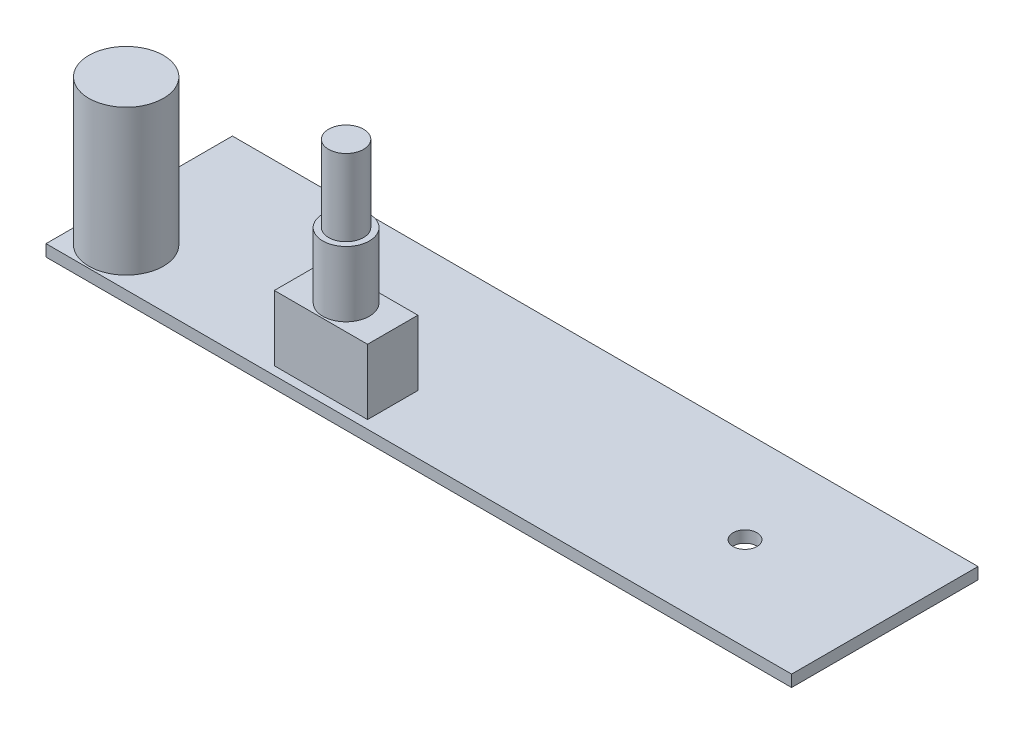
from build123d import *

# Parameters (mm, degrees)
SKETCH1_W                 = 101.6
SKETCH1_H                 = 25.4
BOSS_EXTRUDE1_DEPTH       = 1.5875
F_4_CLEARANCE_HOLE2_D     = 3.2639
F_4_CLEARANCE_HOLE2_DEPTH = 1.5875
SKETCH5_R                 = 5.08
BOSS_EXTRUDE2_DEPTH       = 19.812
SKETCH6_W                 = 12.7
SKETCH6_H                 = 6.858
BOSS_EXTRUDE3_DEPTH       = 8.89
SKETCH7_R                 = 3.175
BOSS_EXTRUDE4_DEPTH       = 8.89
SKETCH8_R                 = 2.38125
BOSS_EXTRUDE5_DEPTH       = 10.414


with BuildPart() as part:
    # Sketch1 → Boss-Extrude1 (new body)
    with BuildSketch(Plane(origin=(0, 0, 0), x_dir=(1, 0, 0), z_dir=(0, 1, 0))):
        with Locations((50.8, 12.7)):
            Rectangle(SKETCH1_W, SKETCH1_H)
    extrude(amount=BOSS_EXTRUDE1_DEPTH)

    # #4 Clearance Hole2
    with Locations(Plane(origin=(0, 1.5875, 0), x_dir=(1, 0, 0), z_dir=(0, 1, 0))):
        with Locations((31.75, 12.7), (82.55, 12.7)):
            Hole(F_4_CLEARANCE_HOLE2_D / 2, depth=F_4_CLEARANCE_HOLE2_DEPTH)

    # Sketch5 → Boss-Extrude2 (add)
    with BuildSketch(Plane(origin=(0, 1.5875, 0), x_dir=(1, 0, 0), z_dir=(0, 1, 0))):
        with Locations((5.588, 5.334)):
            Circle(SKETCH5_R)
    extrude(amount=BOSS_EXTRUDE2_DEPTH)

    # Sketch6 → Boss-Extrude3 (add)
    with BuildSketch(Plane(origin=(0, 1.5875, 0), x_dir=(1, 0, 0), z_dir=(0, 1, 0))):
        with Locations((36.322, 4.572)):
            Rectangle(SKETCH6_W, SKETCH6_H)
    extrude(amount=BOSS_EXTRUDE3_DEPTH)

    # Sketch7 → Boss-Extrude4 (add)
    with BuildSketch(Plane(origin=(0, 10.4775, 0), x_dir=(1, 0, 0), z_dir=(0, 1, 0))):
        with Locations((36.322, 4.572)):
            Circle(SKETCH7_R)
    extrude(amount=BOSS_EXTRUDE4_DEPTH)

    # Sketch8 → Boss-Extrude5 (add)
    with BuildSketch(Plane(origin=(0, 19.3675, 0), x_dir=(1, 0, 0), z_dir=(0, 1, 0))):
        with Locations((36.322, 4.572)):
            Circle(SKETCH8_R)
    extrude(amount=BOSS_EXTRUDE5_DEPTH)


solid = part.part
